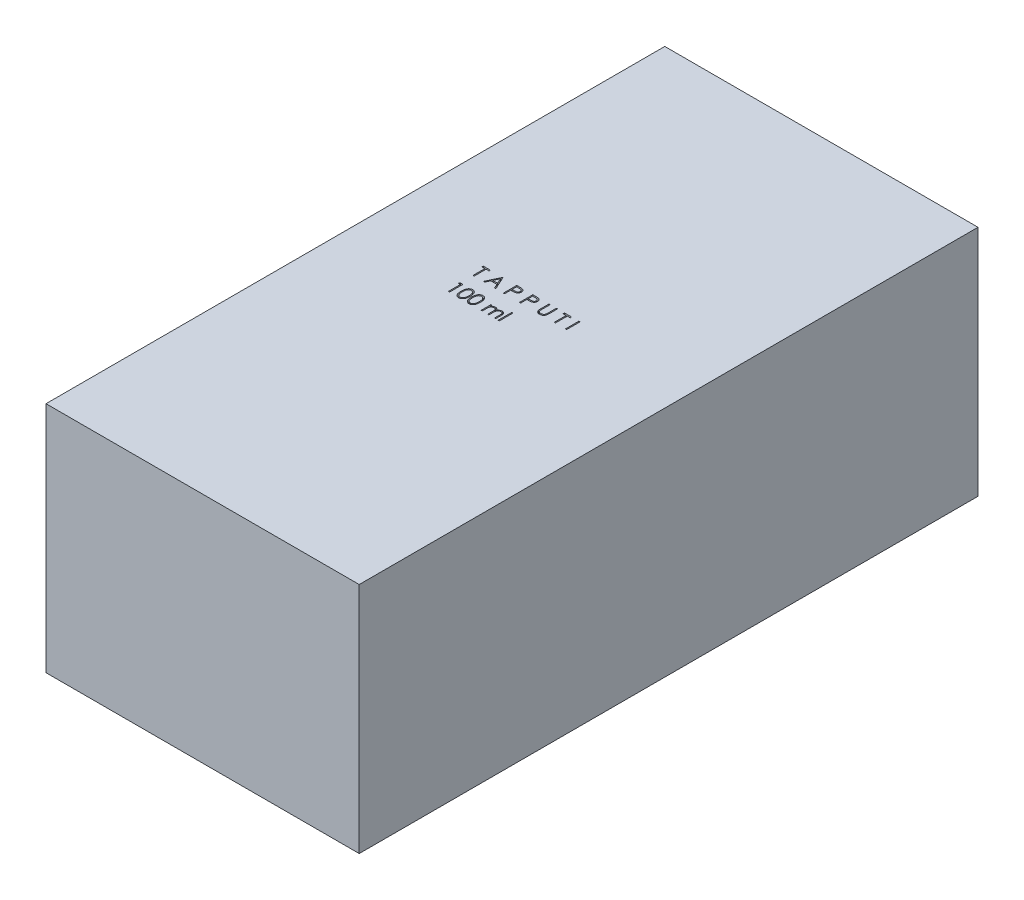
from build123d import *

# Parameters (mm, degrees)
SKETCH1_W           = 82
SKETCH1_H           = 162
BOSS_EXTRUDE1_DEPTH = 61
SKETCH3_W           = 0.314102565
SKETCH3_H           = 3.5
SKETCH3_W_2         = 0.314102564
SKETCH3_H_2         = 3.589743589
CUT_EXTRUDE1_DEPTH  = 10


with BuildPart() as part:
    # Sketch1 → Boss-Extrude1 (new body)
    with BuildSketch(Plane(origin=(0, 0, 0), x_dir=(1, 0, 0), z_dir=(0, 1, 0))):
        Rectangle(SKETCH1_W, SKETCH1_H)
    extrude(amount=-BOSS_EXTRUDE1_DEPTH)

    # Sketch3 → Cut-Extrude1 (cut)
    with BuildSketch(Plane(origin=(0, 0, 0), x_dir=(1, 0, 0), z_dir=(0, 1, 0))):
        Polygon((-14.955128205, 7.091421661), (-14.955128205, 7.45039602), (-13.115384615, 7.45039602), (-13.115384615, 7.091421661), (-13.878205128, 7.091421661), (-13.878205128, 3.95039602), (-14.192307692, 3.95039602), (-14.192307692, 7.091421661), align=None)
        Polygon((-9.794871795, 7.45039602), (-8.179487179, 3.95039602), (-8.520933494, 3.95039602), (-9.038361378, 5.072190892), (-10.625, 5.072190892), (-11.157151442, 3.95039602), (-11.5, 3.95039602), (-9.83974359, 7.45039602), align=None)
        Polygon((-9.820813301, 6.768204514), (-10.454627404, 5.431165251), (-9.203826122, 5.431165251), align=None, mode=Mode.SUBTRACT)
        with BuildLine():
            Line((-6.205128205, 7.45039602), (-5.518729968, 7.45039602))
            add(Edge.make_bspline(
                [(-5.518729968, 7.45039602), (-5.471519062, 7.450344124), (-5.381060869, 7.450244688), (-5.251345813, 7.447229942), (-5.133536082, 7.44320325), (-5.027885701, 7.437621357), (-4.934069603, 7.431024767), (-4.852512303, 7.421772727), (-4.782572747, 7.412112432), (-4.740666297, 7.402291025), (-4.721554487, 7.397811885)],
                knots=[0, 0, 0, 0, 0.000141628, 0.000271366, 0.00038923, 0.000495248, 0.00058876, 0.000671296, 0.000741499, 0.00080036, 0.00080036, 0.00080036, 0.00080036], degree=3))
            add(Edge.make_bspline(
                [(-4.721554487, 7.397811885), (-4.697360953, 7.391189936), (-4.649543976, 7.378102074), (-4.580642933, 7.35188835), (-4.515089088, 7.320806185), (-4.452657529, 7.285382245), (-4.394115446, 7.244096681), (-4.338589405, 7.198623063), (-4.286569425, 7.147911495), (-4.238348033, 7.092530755), (-4.194063235, 7.033410545), (-4.155933553, 6.969668315), (-4.124006326, 6.902377012), (-4.096623054, 6.831583441), (-4.0769146, 6.756693117), (-4.0620677, 6.678226405), (-4.052644072, 6.596191715), (-4.051741511, 6.540131847), (-4.051282051, 6.511593937)],
                knots=[0, 0, 0, 0, 7.5216e-05, 0.00014866, 0.000220794, 0.000292713, 0.000363707, 0.000435434, 0.000507823, 0.000581364, 0.000655543, 0.000729131, 0.000803767, 0.000878771, 0.000956497, 0.001035702, 0.001118238, 0.001203821, 0.001203821, 0.001203821, 0.001203821], degree=3))
            add(Edge.make_bspline(
                [(-4.051282051, 6.511593937), (-4.051703476, 6.48281616), (-4.052528022, 6.426510496), (-4.062424307, 6.344137708), (-4.075754499, 6.265419318), (-4.096251551, 6.190529867), (-4.123097224, 6.119914097), (-4.154589277, 6.052492865), (-4.192572808, 5.989413193), (-4.236217637, 5.930446075), (-4.284769232, 5.875536163), (-4.33802217, 5.825081368), (-4.395761462, 5.77937703), (-4.45780361, 5.738320686), (-4.524753459, 5.702864407), (-4.595595613, 5.671107102), (-4.670945829, 5.644436041), (-4.723088343, 5.63040598), (-4.749599359, 5.623272623)],
                knots=[0, 0, 0, 0, 8.6284e-05, 0.00016882, 0.000248587, 0.000325638, 0.000401297, 0.000474998, 0.000548586, 0.000621785, 0.0006948, 0.0007682, 0.000841564, 0.000915458, 0.000991056, 0.00106858, 0.00114819, 0.001230532, 0.001230532, 0.001230532, 0.001230532], degree=3))
            add(Edge.make_bspline(
                [(-4.749599359, 5.623272623), (-4.771526693, 5.618609641), (-4.81958172, 5.608390447), (-4.898724443, 5.59698199), (-4.990869828, 5.58724439), (-5.095892108, 5.579943252), (-5.213697013, 5.573692884), (-5.344348271, 5.56872479), (-5.488102348, 5.565994936), (-5.588373592, 5.565854143), (-5.64072516, 5.565780635)],
                knots=[0, 0, 0, 0, 6.7238e-05, 0.000147357, 0.000239727, 0.000345177, 0.000463135, 0.000593636, 0.000737393, 0.000894446, 0.000894446, 0.000894446, 0.000894446], degree=3))
            Line((-5.64072516, 5.565780635), (-5.891025641, 5.565780635))
            Line((-5.891025641, 5.565780635), (-5.891025641, 3.95039602))
            Line((-5.891025641, 3.95039602), (-6.205128205, 3.95039602))
            Line((-6.205128205, 3.95039602), (-6.205128205, 7.45039602))
        make_face()
        with BuildLine():
            Line((-5.891025641, 7.091421661), (-5.891025641, 5.924754994))
            Line((-5.891025641, 5.924754994), (-5.278245192, 5.917042655))
            add(Edge.make_bspline(
                [(-5.278245192, 5.917042655), (-5.248325266, 5.917027191), (-5.190565467, 5.916997339), (-5.107129243, 5.920982562), (-5.029719956, 5.925583095), (-4.958575381, 5.932319018), (-4.893663446, 5.941840276), (-4.834875917, 5.951452014), (-4.782668634, 5.965357376), (-4.721569433, 5.984080446), (-4.653486085, 6.016013061), (-4.579418537, 6.062362951), (-4.51664795, 6.121443659), (-4.462329654, 6.187871491), (-4.419223776, 6.26177062), (-4.387667783, 6.340839557), (-4.369126626, 6.424267406), (-4.366640432, 6.481355545), (-4.365384615, 6.510191693)],
                knots=[0, 0, 0, 0, 8.9746e-05, 0.000173253, 0.000250533, 0.00032239, 0.000387534, 0.00044736, 0.000500926, 0.000549486, 0.000638903, 0.000725641, 0.000810488, 0.000896226, 0.000982324, 0.00106604, 0.001150757, 0.001237226, 0.001237226, 0.001237226, 0.001237226], degree=3))
            add(Edge.make_bspline(
                [(-4.365384615, 6.510191693), (-4.366647262, 6.538330206), (-4.369157247, 6.594266089), (-4.38781311, 6.676244849), (-4.419162424, 6.754480554), (-4.462619018, 6.827453639), (-4.515360148, 6.893642443), (-4.576659491, 6.95113957), (-4.646372753, 6.997361273), (-4.711220984, 7.027194554), (-4.76882217, 7.04540983), (-4.81885413, 7.05815467), (-4.875344804, 7.068330277), (-4.938312584, 7.076569779), (-5.007269418, 7.083623241), (-5.082807732, 7.088409218), (-5.164641376, 7.091210674), (-5.221451947, 7.091349629), (-5.250901442, 7.091421661)],
                knots=[0, 0, 0, 0, 8.4371e-05, 0.000167719, 0.000250783, 0.000336277, 0.000421575, 0.000503926, 0.000587348, 0.000671427, 0.000717102, 0.000768457, 0.000826213, 0.000889178, 0.000958942, 0.001034123, 0.001116202, 0.001204546, 0.001204546, 0.001204546, 0.001204546], degree=3))
            Line((-5.250901442, 7.091421661), (-5.891025641, 7.091421661))
        make_face(mode=Mode.SUBTRACT)
        with BuildLine():
            Line((-1.987179487, 7.45039602), (-1.30078125, 7.45039602))
            add(Edge.make_bspline(
                [(-1.30078125, 7.45039602), (-1.253570344, 7.450344124), (-1.163112151, 7.450244688), (-1.033397095, 7.447229942), (-0.915587364, 7.44320325), (-0.809936983, 7.437621357), (-0.716120885, 7.431024767), (-0.634563585, 7.421772727), (-0.564624029, 7.412112432), (-0.522717579, 7.402291025), (-0.503605769, 7.397811885)],
                knots=[0, 0, 0, 0, 0.000141628, 0.000271366, 0.00038923, 0.000495248, 0.00058876, 0.000671296, 0.000741499, 0.00080036, 0.00080036, 0.00080036, 0.00080036], degree=3))
            add(Edge.make_bspline(
                [(-0.503605769, 7.397811885), (-0.479412235, 7.391189936), (-0.431595258, 7.378102074), (-0.362694215, 7.35188835), (-0.29714037, 7.320806185), (-0.234708811, 7.285382245), (-0.176166728, 7.244096681), (-0.120640687, 7.198623063), (-0.068620707, 7.147911495), (-0.020399315, 7.092530755), (0.023885483, 7.033410545), (0.062015165, 6.969668315), (0.093942392, 6.902377012), (0.121325664, 6.831583441), (0.141034118, 6.756693117), (0.155881018, 6.678226405), (0.165304646, 6.596191715), (0.166207207, 6.540131847), (0.166666667, 6.511593937)],
                knots=[0, 0, 0, 0, 7.5216e-05, 0.00014866, 0.000220794, 0.000292713, 0.000363707, 0.000435434, 0.000507823, 0.000581364, 0.000655543, 0.000729131, 0.000803767, 0.000878771, 0.000956497, 0.001035702, 0.001118238, 0.001203821, 0.001203821, 0.001203821, 0.001203821], degree=3))
            add(Edge.make_bspline(
                [(0.166666667, 6.511593937), (0.166245242, 6.48281616), (0.165420696, 6.426510496), (0.155524411, 6.344137708), (0.142194219, 6.265419318), (0.121697167, 6.190529867), (0.094851494, 6.119914097), (0.063359441, 6.052492865), (0.02537591, 5.989413193), (-0.018268919, 5.930446075), (-0.066820514, 5.875536163), (-0.120073452, 5.825081368), (-0.177812744, 5.77937703), (-0.239854892, 5.738320686), (-0.306804741, 5.702864407), (-0.377646895, 5.671107102), (-0.452997111, 5.644436041), (-0.505139625, 5.63040598), (-0.531650641, 5.623272623)],
                knots=[0, 0, 0, 0, 8.6284e-05, 0.00016882, 0.000248587, 0.000325638, 0.000401297, 0.000474998, 0.000548586, 0.000621785, 0.0006948, 0.0007682, 0.000841564, 0.000915458, 0.000991056, 0.00106858, 0.00114819, 0.001230532, 0.001230532, 0.001230532, 0.001230532], degree=3))
            add(Edge.make_bspline(
                [(-0.531650641, 5.623272623), (-0.553577975, 5.618609641), (-0.601633002, 5.608390447), (-0.680775725, 5.59698199), (-0.77292111, 5.58724439), (-0.87794339, 5.579943252), (-0.995748295, 5.573692884), (-1.126399553, 5.56872479), (-1.27015363, 5.565994936), (-1.370424874, 5.565854143), (-1.422776442, 5.565780635)],
                knots=[0, 0, 0, 0, 6.7238e-05, 0.000147357, 0.000239727, 0.000345177, 0.000463135, 0.000593636, 0.000737393, 0.000894446, 0.000894446, 0.000894446, 0.000894446], degree=3))
            Line((-1.422776442, 5.565780635), (-1.673076923, 5.565780635))
            Line((-1.673076923, 5.565780635), (-1.673076923, 3.95039602))
            Line((-1.673076923, 3.95039602), (-1.987179487, 3.95039602))
            Line((-1.987179487, 3.95039602), (-1.987179487, 7.45039602))
        make_face()
        with BuildLine():
            Line((-1.673076923, 7.091421661), (-1.673076923, 5.924754994))
            Line((-1.673076923, 5.924754994), (-1.060296474, 5.917042655))
            add(Edge.make_bspline(
                [(-1.060296474, 5.917042655), (-1.030376549, 5.917027191), (-0.972616749, 5.916997339), (-0.889180525, 5.920982562), (-0.811771238, 5.925583095), (-0.740626663, 5.932319018), (-0.675714728, 5.941840276), (-0.616927199, 5.951452014), (-0.564719916, 5.965357376), (-0.503620715, 5.984080446), (-0.435537367, 6.016013061), (-0.361469819, 6.062362951), (-0.298699232, 6.121443659), (-0.244380936, 6.187871491), (-0.201275058, 6.26177062), (-0.169719065, 6.340839557), (-0.151177908, 6.424267406), (-0.148691714, 6.481355545), (-0.147435897, 6.510191693)],
                knots=[0, 0, 0, 0, 8.9746e-05, 0.000173253, 0.000250533, 0.00032239, 0.000387534, 0.00044736, 0.000500926, 0.000549486, 0.000638903, 0.000725641, 0.000810488, 0.000896226, 0.000982324, 0.00106604, 0.001150757, 0.001237226, 0.001237226, 0.001237226, 0.001237226], degree=3))
            add(Edge.make_bspline(
                [(-0.147435897, 6.510191693), (-0.148698544, 6.538330206), (-0.151208529, 6.594266089), (-0.169864392, 6.676244849), (-0.201213706, 6.754480554), (-0.2446703, 6.827453639), (-0.29741143, 6.893642443), (-0.358710774, 6.95113957), (-0.428424035, 6.997361273), (-0.493272266, 7.027194554), (-0.550873452, 7.04540983), (-0.600905412, 7.05815467), (-0.657396086, 7.068330277), (-0.720363866, 7.076569779), (-0.7893207, 7.083623241), (-0.864859015, 7.088409218), (-0.946692658, 7.091210674), (-1.003503229, 7.091349629), (-1.032952724, 7.091421661)],
                knots=[0, 0, 0, 0, 8.4371e-05, 0.000167719, 0.000250783, 0.000336277, 0.000421575, 0.000503926, 0.000587348, 0.000671427, 0.000717102, 0.000768457, 0.000826213, 0.000889178, 0.000958942, 0.001034123, 0.001116202, 0.001204546, 0.001204546, 0.001204546, 0.001204546], degree=3))
            Line((-1.032952724, 7.091421661), (-1.673076923, 7.091421661))
        make_face(mode=Mode.SUBTRACT)
        with BuildLine():
            Line((2.230769231, 7.45039602), (2.544871795, 7.45039602))
            Line((2.544871795, 7.45039602), (2.544871795, 5.353340731))
            add(Edge.make_bspline(
                [(2.544871795, 5.353340731), (2.544825051, 5.323659996), (2.544736346, 5.267335685), (2.54532886, 5.187167384), (2.546988228, 5.115894925), (2.548034388, 5.053243578), (2.550361722, 4.99950083), (2.552259768, 4.954375519), (2.554700325, 4.918081317), (2.557633443, 4.896900391), (2.558894231, 4.88779586)],
                knots=[0, 0, 0, 0, 8.9042e-05, 0.000168973, 0.000240502, 0.000302917, 0.000356945, 0.000401866, 0.000438432, 0.000465999, 0.000465999, 0.000465999, 0.000465999], degree=3))
            add(Edge.make_bspline(
                [(2.558894231, 4.88779586), (2.56407169, 4.854949096), (2.574134876, 4.791106367), (2.599781254, 4.700198085), (2.635598755, 4.618266627), (2.678041797, 4.542755336), (2.733974409, 4.475765976), (2.800977944, 4.414054323), (2.882155713, 4.360082518), (2.972416318, 4.310731707), (3.069701556, 4.271066624), (3.169112822, 4.24107326), (3.269155801, 4.22279436), (3.336131966, 4.220677821), (3.369391026, 4.219626789)],
                knots=[0, 0, 0, 0, 9.971e-05, 0.000193801, 0.000282365, 0.000367504, 0.000452699, 0.000543015, 0.000639862, 0.000744331, 0.000851226, 0.000954377, 0.001055468, 0.001155185, 0.001155185, 0.001155185, 0.001155185], degree=3))
            add(Edge.make_bspline(
                [(3.369391026, 4.219626789), (3.397944766, 4.220700639), (3.454887328, 4.222842138), (3.539493759, 4.236103569), (3.621893867, 4.260004134), (3.702494547, 4.290843893), (3.778045532, 4.331591484), (3.848588974, 4.378662323), (3.911552908, 4.433873199), (3.969010906, 4.494973544), (4.019045842, 4.563913344), (4.062416983, 4.639191482), (4.097942913, 4.721940829), (4.115486438, 4.780095251), (4.124499199, 4.80997134)],
                knots=[0, 0, 0, 0, 8.5678e-05, 0.00017086, 0.000256092, 0.000342674, 0.000429242, 0.000513055, 0.000596556, 0.000679898, 0.000764179, 0.00085149, 0.000940054, 0.001033621, 0.001033621, 0.001033621, 0.001033621], degree=3))
            add(Edge.make_bspline(
                [(4.124499199, 4.80997134), (4.127499324, 4.822319915), (4.134184812, 4.849837515), (4.140431857, 4.896358805), (4.146938383, 4.951248169), (4.151452953, 5.014899982), (4.155854173, 5.087100955), (4.158487246, 5.168227212), (4.159704279, 5.257984173), (4.160066959, 5.320621335), (4.16025641, 5.353340731)],
                knots=[0, 0, 0, 0, 3.81e-05, 8.4902e-05, 0.000140649, 0.000203941, 0.000276279, 0.000357657, 0.000447412, 0.000545571, 0.000545571, 0.000545571, 0.000545571], degree=3))
            Line((4.16025641, 5.353340731), (4.16025641, 7.45039602))
            Line((4.16025641, 7.45039602), (4.474358974, 7.45039602))
            Line((4.474358974, 7.45039602), (4.474358974, 5.336513808))
            add(Edge.make_bspline(
                [(4.474358974, 5.336513808), (4.474104854, 5.298415429), (4.473608923, 5.224064127), (4.469308346, 5.115112768), (4.462451346, 5.011759786), (4.452763258, 4.91399129), (4.439926255, 4.82215713), (4.425651035, 4.735452362), (4.407471502, 4.65449937), (4.3862381, 4.578666952), (4.361964552, 4.506481439), (4.330523404, 4.437972824), (4.295098904, 4.371058424), (4.253084251, 4.306750315), (4.205872868, 4.244763762), (4.152421188, 4.185474687), (4.094497027, 4.127935641), (4.031137467, 4.073622575), (3.963386942, 4.023813898), (3.891446984, 3.980016127), (3.815870215, 3.942992509), (3.736853088, 3.912516585), (3.654361886, 3.889601986), (3.568394526, 3.87252683), (3.478755333, 3.862824532), (3.417790676, 3.861382602), (3.386919071, 3.86065243)],
                knots=[0, 0, 0, 0, 0.000114291, 0.000223047, 0.000327049, 0.000424998, 0.000517708, 0.000605194, 0.000688542, 0.000766455, 0.0008414, 0.000916717, 0.000992315, 0.001068354, 0.001146882, 0.001225836, 0.001307639, 0.001391671, 0.001475952, 0.001559641, 0.001643989, 0.001728103, 0.001813335, 0.001900511, 0.00199079, 0.002083404, 0.002083404, 0.002083404, 0.002083404], degree=3))
            add(Edge.make_bspline(
                [(3.386919071, 3.86065243), (3.353249968, 3.861437195), (3.287191309, 3.862976902), (3.189853242, 3.871799652), (3.096539045, 3.888418047), (3.006263168, 3.90957799), (2.920254671, 3.938761728), (2.837361227, 3.972859852), (2.759002546, 4.014737113), (2.683907417, 4.061330506), (2.614082661, 4.113755144), (2.549985258, 4.170895318), (2.491509387, 4.231835695), (2.439640691, 4.297236061), (2.393519806, 4.366587768), (2.353789593, 4.440087008), (2.319676349, 4.517705324), (2.302069782, 4.571658524), (2.293169071, 4.59893368)],
                knots=[0, 0, 0, 0, 0.000101022, 0.000198206, 0.000292839, 0.000385177, 0.00047608, 0.000565014, 0.000653769, 0.000742283, 0.000829923, 0.000915339, 0.000999643, 0.001082971, 0.00116542, 0.001249186, 0.001333332, 0.001419362, 0.001419362, 0.001419362, 0.001419362], degree=3))
            add(Edge.make_bspline(
                [(2.293169071, 4.59893368), (2.287991912, 4.617566255), (2.276762541, 4.657980724), (2.264737243, 4.724867212), (2.254628162, 4.80188213), (2.245122603, 4.889030748), (2.239513645, 4.986380615), (2.234596207, 5.093889531), (2.230734588, 5.211687492), (2.23075736, 5.293742008), (2.230769231, 5.336513808)],
                knots=[0, 0, 0, 0, 5.799e-05, 0.000125782, 0.000203619, 0.000291034, 0.000388694, 0.000496078, 0.000613919, 0.000742226, 0.000742226, 0.000742226, 0.000742226], degree=3))
            Line((2.230769231, 5.336513808), (2.230769231, 7.45039602))
        make_face()
        Polygon((6.314102564, 7.091421661), (6.314102564, 7.45039602), (8.153846154, 7.45039602), (8.153846154, 7.091421661), (7.391025641, 7.091421661), (7.391025641, 3.95039602), (7.076923077, 3.95039602), (7.076923077, 7.091421661), align=None)
        with Locations((10.19551282, 5.70039602)):
            Rectangle(SKETCH3_W, SKETCH3_H)
        Polygon((-14.121494391, 0.617062687), (-13.474358974, 0.617062687), (-13.474358974, -2.882937313), (-13.788461538, -2.882937313), (-13.788461538, 0.258088328), (-14.326923077, 0.258088328), align=None)
        with BuildLine():
            add(Edge.make_bspline(
                [(-12.173076923, -1.134339557), (-12.172748905, -1.078242169), (-12.172111725, -0.969272185), (-12.165023304, -0.810487543), (-12.153247962, -0.661527254), (-12.137110589, -0.522384188), (-12.117472609, -0.393022423), (-12.091257122, -0.273787666), (-12.061444319, -0.16412806), (-12.026891874, -0.063686011), (-11.987904085, 0.028891692), (-11.945469824, 0.115316893), (-11.897905029, 0.195458826), (-11.847928116, 0.270596616), (-11.793516045, 0.339500311), (-11.736217254, 0.403142973), (-11.673795378, 0.460053724), (-11.60837237, 0.511900026), (-11.539355905, 0.557349498), (-11.468713239, 0.597382236), (-11.395958133, 0.631582104), (-11.320891951, 0.658472539), (-11.244189393, 0.680683386), (-11.165582326, 0.695872334), (-11.084940962, 0.705429242), (-11.030509527, 0.70634291), (-11.002904647, 0.706806276)],
                knots=[0, 0, 0, 0, 0.000168282, 0.000326891, 0.000476705, 0.00061646, 0.000747059, 0.00086904, 0.000982494, 0.001087814, 0.001187428, 0.001283689, 0.001376399, 0.001466822, 0.001554203, 0.001639568, 0.001723424, 0.001807301, 0.001889751, 0.001971063, 0.002050735, 0.002130583, 0.002210036, 0.002290062, 0.002370508, 0.002453288, 0.002453288, 0.002453288, 0.002453288], degree=3))
            add(Edge.make_bspline(
                [(-11.002904647, 0.706806276), (-10.975069169, 0.706318461), (-10.91971316, 0.70534835), (-10.837872785, 0.696024408), (-10.757923103, 0.680553285), (-10.680204964, 0.65863231), (-10.604079978, 0.631436633), (-10.53014357, 0.597349516), (-10.457936489, 0.557670649), (-10.388606201, 0.511046772), (-10.321391586, 0.459064495), (-10.257943623, 0.400301827), (-10.198256537, 0.335352107), (-10.141581232, 0.264910243), (-10.089525634, 0.187625159), (-10.039952202, 0.104841049), (-9.995580166, 0.015110184), (-9.952845491, -0.080070284), (-9.915958504, -0.183333943), (-9.882692259, -0.294098703), (-9.85581329, -0.41367289), (-9.833424018, -0.541429135), (-9.816079122, -0.677836619), (-9.80344648, -0.822602934), (-9.796773395, -0.975823325), (-9.795516694, -1.080581174), (-9.794871795, -1.134339557)],
                knots=[0, 0, 0, 0, 8.3481e-05, 0.000166017, 0.000246731, 0.000327534, 0.000408041, 0.000488986, 0.000571522, 0.000654944, 0.000739373, 0.000826202, 0.000914021, 0.001003809, 0.001097153, 0.001193347, 0.001293057, 0.001397277, 0.001506176, 0.001621751, 0.001744038, 0.001873599, 0.002010742, 0.002156422, 0.002309427, 0.002470709, 0.002470709, 0.002470709, 0.002470709], degree=3))
            add(Edge.make_bspline(
                [(-9.794871795, -1.134339557), (-9.795523379, -1.187863465), (-9.796792965, -1.292152617), (-9.803371672, -1.444683592), (-9.816330303, -1.588681635), (-9.832540292, -1.724492098), (-9.854991255, -1.851549717), (-9.882596421, -1.970294165), (-9.913246744, -2.081238237), (-9.951081538, -2.183473048), (-9.992492248, -2.278424771), (-10.037547444, -2.36709192), (-10.08581727, -2.450258212), (-10.138406015, -2.527257959), (-10.194459429, -2.598636616), (-10.255177217, -2.663134239), (-10.318847802, -2.722304911), (-10.386260218, -2.774956538), (-10.45667177, -2.821041343), (-10.528630846, -2.862255193), (-10.60341423, -2.895487888), (-10.679327183, -2.924022929), (-10.757455549, -2.945823381), (-10.837701939, -2.960897237), (-10.919658175, -2.971469085), (-10.97505974, -2.972275565), (-11.002904647, -2.972680903)],
                knots=[0, 0, 0, 0, 0.000160581, 0.000312886, 0.000457868, 0.000594226, 0.000723097, 0.000844701, 0.000959884, 0.001068125, 0.001171421, 0.001270505, 0.001366343, 0.001459687, 0.001550023, 0.00163832, 0.001725149, 0.001810562, 0.001894568, 0.001977446, 0.00205903, 0.002139777, 0.00222058, 0.002301983, 0.002384599, 0.00246808, 0.00246808, 0.00246808, 0.00246808], degree=3))
            add(Edge.make_bspline(
                [(-11.002904647, -2.972680903), (-11.030508761, -2.972214548), (-11.084938686, -2.971294986), (-11.165591112, -2.961781254), (-11.243873555, -2.946485751), (-11.320172309, -2.925069147), (-11.394878824, -2.898854311), (-11.466975111, -2.864700627), (-11.537262795, -2.825366558), (-11.605554351, -2.780571137), (-11.670566512, -2.729249453), (-11.732665117, -2.672485165), (-11.790290136, -2.608861754), (-11.843924232, -2.53938383), (-11.89489832, -2.464690588), (-11.941787693, -2.383762215), (-11.985158547, -2.296919605), (-12.024802038, -2.203601694), (-12.059950701, -2.102446766), (-12.090998409, -1.992297588), (-12.115512567, -1.872181951), (-12.136495522, -1.743064584), (-12.153419905, -1.604390654), (-12.164974231, -1.456084876), (-12.172115546, -1.298239667), (-12.172750616, -1.189969892), (-12.173076923, -1.134339557)],
                knots=[0, 0, 0, 0, 8.278e-05, 0.000163226, 0.000243252, 0.00032184, 0.00040079, 0.000480463, 0.00056082, 0.000642298, 0.000725191, 0.000809047, 0.000894412, 0.000982346, 0.001072188, 0.001165503, 0.001262704, 0.001363236, 0.001469448, 0.001583766, 0.001706286, 0.001836995, 0.001976138, 0.002125253, 0.002283161, 0.002450041, 0.002450041, 0.002450041, 0.002450041], degree=3))
        make_face()
        with BuildLine():
            add(Edge.make_bspline(
                [(-11.858974359, -1.132937313), (-11.858854912, -1.179686012), (-11.858623089, -1.270416057), (-11.852566888, -1.402259318), (-11.844316656, -1.525229647), (-11.833675359, -1.639483183), (-11.81787241, -1.744633196), (-11.800165622, -1.841402879), (-11.778617533, -1.929280116), (-11.753122515, -2.008867927), (-11.724083418, -2.081516995), (-11.692377554, -2.14911821), (-11.658316832, -2.212470147), (-11.620197681, -2.271003755), (-11.578682618, -2.324909919), (-11.534709359, -2.375142751), (-11.486636774, -2.419939733), (-11.420133032, -2.473666588), (-11.332336557, -2.529185722), (-11.221716102, -2.577531811), (-11.108047651, -2.607914268), (-11.030896401, -2.611778024), (-10.992387821, -2.613706544)],
                knots=[0, 0, 0, 0, 0.000140231, 0.000272162, 0.000395845, 0.00050998, 0.000616273, 0.00071473, 0.000805025, 0.000887508, 0.000965234, 0.00103957, 0.001111417, 0.001180842, 0.001248855, 0.001315406, 0.001380877, 0.0014457, 0.001571746, 0.00169106, 0.001806864, 0.001922266, 0.001922266, 0.001922266, 0.001922266], degree=3))
            add(Edge.make_bspline(
                [(-10.992387821, -2.613706544), (-10.953630149, -2.612108763), (-10.876194826, -2.608916501), (-10.763061031, -2.578117763), (-10.65323076, -2.531648224), (-10.56715882, -2.476700718), (-10.501676277, -2.424372389), (-10.454759287, -2.379757741), (-10.411697238, -2.329801873), (-10.370855163, -2.275902577), (-10.333396088, -2.217030093), (-10.29933295, -2.153467518), (-10.268249602, -2.08503834), (-10.250540556, -2.037268601), (-10.241486378, -2.012845166)],
                knots=[0, 0, 0, 0, 0.000116044, 0.000231848, 0.000349318, 0.000472837, 0.000536674, 0.000600645, 0.000666733, 0.000734322, 0.000803367, 0.000875831, 0.000950509, 0.001028633, 0.001028633, 0.001028633, 0.001028633], degree=3))
            add(Edge.make_bspline(
                [(-10.241486378, -2.012845166), (-10.23093461, -1.981615426), (-10.209509997, -1.918205662), (-10.181898222, -1.81984201), (-10.160152823, -1.716639246), (-10.140589457, -1.60921413), (-10.127236401, -1.496774428), (-10.116488588, -1.379668045), (-10.110157901, -1.257806682), (-10.10937315, -1.175011691), (-10.108974359, -1.132937313)],
                knots=[0, 0, 0, 0, 9.8886e-05, 0.00020078, 0.000306259, 0.000415188, 0.00052824, 0.000645799, 0.000767957, 0.000894177, 0.000894177, 0.000894177, 0.000894177], degree=3))
            add(Edge.make_bspline(
                [(-10.108974359, -1.132937313), (-10.109524548, -1.090869741), (-10.110600836, -1.008576576), (-10.114714824, -0.888058395), (-10.125338398, -0.773590635), (-10.137137517, -0.664680162), (-10.154534738, -0.561929859), (-10.173292545, -0.464479554), (-10.198493757, -0.373536529), (-10.225413532, -0.287676947), (-10.256223928, -0.207876293), (-10.290139662, -0.133762506), (-10.326361421, -0.064977782), (-10.365703661, -0.00171084), (-10.407699344, 0.056321703), (-10.453456894, 0.107956297), (-10.501161266, 0.154793265), (-10.567978452, 0.208255835), (-10.655452742, 0.26276753), (-10.764298389, 0.31293329), (-10.877569034, 0.341741582), (-10.954142488, 0.34580327), (-10.992387821, 0.347831917)],
                knots=[0, 0, 0, 0, 0.000126219, 0.000246912, 0.000361616, 0.00047102, 0.00057545, 0.000674176, 0.000768567, 0.000858368, 0.000944043, 0.001024988, 0.001102772, 0.001177091, 0.00124833, 0.001317386, 0.001383826, 0.001448649, 0.001573728, 0.001692043, 0.001806995, 0.001921698, 0.001921698, 0.001921698, 0.001921698], degree=3))
            add(Edge.make_bspline(
                [(-10.992387821, 0.347831917), (-11.031098413, 0.345800471), (-11.108590118, 0.341733877), (-11.223038073, 0.313040623), (-11.332742425, 0.263027657), (-11.419985399, 0.208075285), (-11.486849186, 0.155736973), (-11.533931879, 0.110350519), (-11.578078051, 0.060704265), (-11.618745751, 0.00630235), (-11.656835035, -0.052163017), (-11.691816047, -0.115151782), (-11.723333377, -0.182983146), (-11.752417913, -0.255599582), (-11.777990701, -0.335180526), (-11.799084664, -0.42294952), (-11.818571717, -0.519411412), (-11.832366986, -0.62513092), (-11.844630742, -0.739413073), (-11.85251209, -0.862690391), (-11.858643348, -0.994754772), (-11.858861812, -1.08595393), (-11.858974359, -1.132937313)],
                knots=[0, 0, 0, 0, 0.000116101, 0.000232413, 0.000351368, 0.000476447, 0.000540832, 0.000605795, 0.000672346, 0.000739935, 0.00080936, 0.000881545, 0.00095588, 0.001033607, 0.001116089, 0.001206384, 0.001304286, 0.001411174, 0.001526077, 0.001649061, 0.001781692, 0.001922624, 0.001922624, 0.001922624, 0.001922624], degree=3))
        make_face(mode=Mode.SUBTRACT)
        with BuildLine():
            add(Edge.make_bspline(
                [(-9.480769231, -1.134339557), (-9.480441213, -1.078242169), (-9.479804033, -0.969272185), (-9.472715612, -0.810487543), (-9.460940269, -0.661527254), (-9.444802897, -0.522384188), (-9.425164916, -0.393022423), (-9.39894943, -0.273787666), (-9.369136627, -0.16412806), (-9.334584181, -0.063686011), (-9.295596392, 0.028891692), (-9.253162132, 0.115316893), (-9.205597337, 0.195458826), (-9.155620424, 0.270596616), (-9.101208353, 0.339500311), (-9.043909562, 0.403142973), (-8.981487686, 0.460053724), (-8.916064678, 0.511900026), (-8.847048213, 0.557349498), (-8.776405547, 0.597382236), (-8.703650441, 0.631582104), (-8.628584258, 0.658472539), (-8.5518817, 0.680683386), (-8.473274634, 0.695872334), (-8.39263327, 0.705429242), (-8.338201835, 0.70634291), (-8.310596955, 0.706806276)],
                knots=[0, 0, 0, 0, 0.000168282, 0.000326891, 0.000476705, 0.00061646, 0.000747059, 0.00086904, 0.000982494, 0.001087814, 0.001187428, 0.001283689, 0.001376399, 0.001466822, 0.001554203, 0.001639568, 0.001723424, 0.001807301, 0.001889751, 0.001971063, 0.002050735, 0.002130583, 0.002210036, 0.002290062, 0.002370508, 0.002453288, 0.002453288, 0.002453288, 0.002453288], degree=3))
            add(Edge.make_bspline(
                [(-8.310596955, 0.706806276), (-8.282761477, 0.706318461), (-8.227405468, 0.70534835), (-8.145565093, 0.696024408), (-8.065615411, 0.680553285), (-7.987897272, 0.65863231), (-7.911772286, 0.631436633), (-7.837835878, 0.597349516), (-7.765628796, 0.557670649), (-7.696298509, 0.511046772), (-7.629083893, 0.459064495), (-7.56563593, 0.400301827), (-7.505948845, 0.335352107), (-7.449273539, 0.264910243), (-7.397217942, 0.187625159), (-7.34764451, 0.104841049), (-7.303272474, 0.015110184), (-7.260537799, -0.080070284), (-7.223650812, -0.183333943), (-7.190384567, -0.294098703), (-7.163505598, -0.41367289), (-7.141116326, -0.541429135), (-7.12377143, -0.677836619), (-7.111138788, -0.822602934), (-7.104465703, -0.975823325), (-7.103209001, -1.080581174), (-7.102564103, -1.134339557)],
                knots=[0, 0, 0, 0, 8.3481e-05, 0.000166017, 0.000246731, 0.000327534, 0.000408041, 0.000488986, 0.000571522, 0.000654944, 0.000739373, 0.000826202, 0.000914021, 0.001003809, 0.001097153, 0.001193347, 0.001293057, 0.001397277, 0.001506176, 0.001621751, 0.001744038, 0.001873599, 0.002010742, 0.002156422, 0.002309427, 0.002470709, 0.002470709, 0.002470709, 0.002470709], degree=3))
            add(Edge.make_bspline(
                [(-7.102564103, -1.134339557), (-7.103215687, -1.187863465), (-7.104485273, -1.292152617), (-7.11106398, -1.444683592), (-7.124022611, -1.588681635), (-7.140232599, -1.724492098), (-7.162683562, -1.851549717), (-7.190288728, -1.970294165), (-7.220939051, -2.081238237), (-7.258773845, -2.183473048), (-7.300184556, -2.278424771), (-7.345239752, -2.36709192), (-7.393509578, -2.450258212), (-7.446098323, -2.527257959), (-7.502151736, -2.598636616), (-7.562869525, -2.663134239), (-7.62654011, -2.722304911), (-7.693952526, -2.774956538), (-7.764364077, -2.821041343), (-7.836323154, -2.862255193), (-7.911106537, -2.895487888), (-7.98701949, -2.924022929), (-8.065147856, -2.945823381), (-8.145394247, -2.960897237), (-8.227350483, -2.971469085), (-8.282752048, -2.972275565), (-8.310596955, -2.972680903)],
                knots=[0, 0, 0, 0, 0.000160581, 0.000312886, 0.000457868, 0.000594226, 0.000723097, 0.000844701, 0.000959884, 0.001068125, 0.001171421, 0.001270505, 0.001366343, 0.001459687, 0.001550023, 0.00163832, 0.001725149, 0.001810562, 0.001894568, 0.001977446, 0.00205903, 0.002139777, 0.00222058, 0.002301983, 0.002384599, 0.00246808, 0.00246808, 0.00246808, 0.00246808], degree=3))
            add(Edge.make_bspline(
                [(-8.310596955, -2.972680903), (-8.338201069, -2.972214548), (-8.392630994, -2.971294986), (-8.473283419, -2.961781254), (-8.551565863, -2.946485751), (-8.627864617, -2.925069147), (-8.702571132, -2.898854311), (-8.774667419, -2.864700627), (-8.844955102, -2.825366558), (-8.913246658, -2.780571137), (-8.978258819, -2.729249453), (-9.040357425, -2.672485165), (-9.097982444, -2.608861754), (-9.151616539, -2.53938383), (-9.202590628, -2.464690588), (-9.249480001, -2.383762215), (-9.292850855, -2.296919605), (-9.332494346, -2.203601694), (-9.367643009, -2.102446766), (-9.398690717, -1.992297588), (-9.423204875, -1.872181951), (-9.44418783, -1.743064584), (-9.461112213, -1.604390654), (-9.472666538, -1.456084876), (-9.479807853, -1.298239667), (-9.480442924, -1.189969892), (-9.480769231, -1.134339557)],
                knots=[0, 0, 0, 0, 8.278e-05, 0.000163226, 0.000243252, 0.00032184, 0.00040079, 0.000480463, 0.00056082, 0.000642298, 0.000725191, 0.000809047, 0.000894412, 0.000982346, 0.001072188, 0.001165503, 0.001262704, 0.001363236, 0.001469448, 0.001583766, 0.001706286, 0.001836995, 0.001976138, 0.002125253, 0.002283161, 0.002450041, 0.002450041, 0.002450041, 0.002450041], degree=3))
        make_face()
        with BuildLine():
            add(Edge.make_bspline(
                [(-9.166666667, -1.132937313), (-9.16654722, -1.179686012), (-9.166315396, -1.270416057), (-9.160259196, -1.402259318), (-9.152008964, -1.525229647), (-9.141367667, -1.639483183), (-9.125564718, -1.744633196), (-9.10785793, -1.841402879), (-9.086309841, -1.929280116), (-9.060814823, -2.008867927), (-9.031775726, -2.081516995), (-9.000069862, -2.14911821), (-8.966009139, -2.212470147), (-8.927889989, -2.271003755), (-8.886374925, -2.324909919), (-8.842401666, -2.375142751), (-8.794329082, -2.419939733), (-8.72782534, -2.473666588), (-8.640028865, -2.529185722), (-8.52940841, -2.577531811), (-8.415739959, -2.607914268), (-8.338588709, -2.611778024), (-8.300080128, -2.613706544)],
                knots=[0, 0, 0, 0, 0.000140231, 0.000272162, 0.000395845, 0.00050998, 0.000616273, 0.00071473, 0.000805025, 0.000887508, 0.000965234, 0.00103957, 0.001111417, 0.001180842, 0.001248855, 0.001315406, 0.001380877, 0.0014457, 0.001571746, 0.00169106, 0.001806864, 0.001922266, 0.001922266, 0.001922266, 0.001922266], degree=3))
            add(Edge.make_bspline(
                [(-8.300080128, -2.613706544), (-8.261322457, -2.612108763), (-8.183887133, -2.608916501), (-8.070753338, -2.578117763), (-7.960923068, -2.531648224), (-7.874851128, -2.476700718), (-7.809368584, -2.424372389), (-7.762451594, -2.379757741), (-7.719389546, -2.329801873), (-7.678547471, -2.275902577), (-7.641088395, -2.217030093), (-7.607025258, -2.153467518), (-7.57594191, -2.08503834), (-7.558232864, -2.037268601), (-7.549178686, -2.012845166)],
                knots=[0, 0, 0, 0, 0.000116044, 0.000231848, 0.000349318, 0.000472837, 0.000536674, 0.000600645, 0.000666733, 0.000734322, 0.000803367, 0.000875831, 0.000950509, 0.001028633, 0.001028633, 0.001028633, 0.001028633], degree=3))
            add(Edge.make_bspline(
                [(-7.549178686, -2.012845166), (-7.538626918, -1.981615426), (-7.517202304, -1.918205662), (-7.48959053, -1.81984201), (-7.467845131, -1.716639246), (-7.448281765, -1.60921413), (-7.434928709, -1.496774428), (-7.424180896, -1.379668045), (-7.417850209, -1.257806682), (-7.417065458, -1.175011691), (-7.416666667, -1.132937313)],
                knots=[0, 0, 0, 0, 9.8886e-05, 0.00020078, 0.000306259, 0.000415188, 0.00052824, 0.000645799, 0.000767957, 0.000894177, 0.000894177, 0.000894177, 0.000894177], degree=3))
            add(Edge.make_bspline(
                [(-7.416666667, -1.132937313), (-7.417216856, -1.090869741), (-7.418293144, -1.008576576), (-7.422407131, -0.888058395), (-7.433030706, -0.773590635), (-7.444829825, -0.664680162), (-7.462227046, -0.561929859), (-7.480984853, -0.464479554), (-7.506186065, -0.373536529), (-7.53310584, -0.287676947), (-7.563916235, -0.207876293), (-7.59783197, -0.133762506), (-7.634053729, -0.064977782), (-7.673395969, -0.00171084), (-7.715391652, 0.056321703), (-7.761149201, 0.107956297), (-7.808853574, 0.154793265), (-7.87567076, 0.208255835), (-7.96314505, 0.26276753), (-8.071990697, 0.31293329), (-8.185261341, 0.341741582), (-8.261834795, 0.34580327), (-8.300080128, 0.347831917)],
                knots=[0, 0, 0, 0, 0.000126219, 0.000246912, 0.000361616, 0.00047102, 0.00057545, 0.000674176, 0.000768567, 0.000858368, 0.000944043, 0.001024988, 0.001102772, 0.001177091, 0.00124833, 0.001317386, 0.001383826, 0.001448649, 0.001573728, 0.001692043, 0.001806995, 0.001921698, 0.001921698, 0.001921698, 0.001921698], degree=3))
            add(Edge.make_bspline(
                [(-8.300080128, 0.347831917), (-8.33879072, 0.345800471), (-8.416282426, 0.341733877), (-8.530730381, 0.313040623), (-8.640434732, 0.263027657), (-8.727677707, 0.208075285), (-8.794541493, 0.155736973), (-8.841624187, 0.110350519), (-8.885770359, 0.060704265), (-8.926438059, 0.00630235), (-8.964527342, -0.052163017), (-8.999508355, -0.115151782), (-9.031025685, -0.182983146), (-9.060110221, -0.255599582), (-9.085683009, -0.335180526), (-9.106776972, -0.42294952), (-9.126264025, -0.519411412), (-9.140059294, -0.62513092), (-9.15232305, -0.739413073), (-9.160204398, -0.862690391), (-9.166335655, -0.994754772), (-9.16655412, -1.08595393), (-9.166666667, -1.132937313)],
                knots=[0, 0, 0, 0, 0.000116101, 0.000232413, 0.000351368, 0.000476447, 0.000540832, 0.000605795, 0.000672346, 0.000739935, 0.00080936, 0.000881545, 0.00095588, 0.001033607, 0.001116089, 0.001206384, 0.001304286, 0.001411174, 0.001526077, 0.001649061, 0.001781692, 0.001922624, 0.001922624, 0.001922624, 0.001922624], degree=3))
        make_face(mode=Mode.SUBTRACT)
        with BuildLine():
            Line((-5.217948718, -0.325245006), (-4.903846154, -0.325245006))
            Line((-4.903846154, -0.325245006), (-4.903846154, -0.769756224))
            add(Edge.make_bspline(
                [(-4.903846154, -0.769756224), (-4.875562204, -0.730868622), (-4.821367444, -0.656356249), (-4.732501792, -0.558165965), (-4.643725679, -0.47483781), (-4.579792298, -0.431094938), (-4.549078526, -0.410080743)],
                knots=[0, 0, 0, 0, 0.000144152, 0.000276209, 0.000396804, 0.000508302, 0.000508302, 0.000508302, 0.000508302], degree=3))
            add(Edge.make_bspline(
                [(-4.549078526, -0.410080743), (-4.507213863, -0.390075378), (-4.424215964, -0.350414164), (-4.292796739, -0.310180605), (-4.158322069, -0.285455504), (-4.067513855, -0.282074131), (-4.021834936, -0.280373211)],
                knots=[0, 0, 0, 0, 0.000139031, 0.000275633, 0.000410962, 0.000547939, 0.000547939, 0.000547939, 0.000547939], degree=3))
            add(Edge.make_bspline(
                [(-4.021834936, -0.280373211), (-3.990941939, -0.281418502), (-3.92980636, -0.283487076), (-3.83922227, -0.296947111), (-3.751363658, -0.320213284), (-3.666749629, -0.352620608), (-3.58702895, -0.391867295), (-3.513939752, -0.437917003), (-3.448315544, -0.489614078), (-3.390189493, -0.549293011), (-3.337920467, -0.61862961), (-3.28984162, -0.699493859), (-3.245416408, -0.79370152), (-3.220795099, -0.862068061), (-3.207832532, -0.898061512)],
                knots=[0, 0, 0, 0, 9.2678e-05, 0.000183405, 0.000274048, 0.000364807, 0.000454797, 0.00054019, 0.000623517, 0.000704829, 0.000789387, 0.000883415, 0.000986597, 0.001101318, 0.001101318, 0.001101318, 0.001101318], degree=3))
            add(Edge.make_bspline(
                [(-3.207832532, -0.898061512), (-3.194121281, -0.873337093), (-3.167139464, -0.824682908), (-3.121833827, -0.755824646), (-3.07436603, -0.691417854), (-3.024331537, -0.631411429), (-2.97190695, -0.576101699), (-2.91684555, -0.525305797), (-2.859460768, -0.478805584), (-2.779668528, -0.424482424), (-2.675855921, -0.366781243), (-2.544967806, -0.316752799), (-2.408817635, -0.28583667), (-2.316399937, -0.282206398), (-2.269731571, -0.280373211)],
                knots=[0, 0, 0, 0, 8.4789e-05, 0.000166854, 0.000247064, 0.000324714, 0.000401089, 0.000475513, 0.000549314, 0.000622436, 0.0007649, 0.000904487, 0.001041601, 0.001181469, 0.001181469, 0.001181469, 0.001181469], degree=3))
            add(Edge.make_bspline(
                [(-2.269731571, -0.280373211), (-2.226850108, -0.281990432), (-2.142926921, -0.28515549), (-2.020749656, -0.310008963), (-1.90680785, -0.35268661), (-1.801330774, -0.410920247), (-1.706170961, -0.48409943), (-1.623454652, -0.571168268), (-1.553684288, -0.671510891), (-1.508105649, -0.76590288), (-1.477190384, -0.849238212), (-1.45812915, -0.920244504), (-1.441289455, -0.998396057), (-1.42730821, -1.083786318), (-1.417089658, -1.176716926), (-1.409518942, -1.277035802), (-1.404394869, -1.384820914), (-1.404032796, -1.459186414), (-1.403846154, -1.497520647)],
                knots=[0, 0, 0, 0, 0.000128581, 0.000251645, 0.00037211, 0.000492305, 0.000611786, 0.000730807, 0.000851198, 0.000976936, 0.001044145, 0.001117629, 0.001197252, 0.00128393, 0.001377074, 0.001477631, 0.001585715, 0.001700707, 0.001700707, 0.001700707, 0.001700707], degree=3))
            Line((-1.403846154, -1.497520647), (-1.403846154, -2.882937313))
            Line((-1.403846154, -2.882937313), (-1.717948718, -2.882937313))
            Line((-1.717948718, -2.882937313), (-1.717948718, -1.496118403))
            add(Edge.make_bspline(
                [(-1.717948718, -1.496118403), (-1.718026601, -1.463397829), (-1.71817628, -1.400513862), (-1.720869912, -1.310261411), (-1.725945226, -1.227993054), (-1.731879865, -1.153820966), (-1.740123674, -1.087572177), (-1.750769606, -1.029379759), (-1.762047286, -0.978785947), (-1.780783277, -0.9226999), (-1.810731168, -0.860829689), (-1.856348648, -0.794106113), (-1.913818755, -0.736025313), (-1.980178911, -0.685606996), (-2.055727356, -0.644613355), (-2.138992079, -0.615337346), (-2.229456131, -0.597214467), (-2.292078919, -0.595408452), (-2.324419071, -0.594475775)],
                knots=[0, 0, 0, 0, 9.816e-05, 0.000188648, 0.000270826, 0.000345412, 0.000411852, 0.000470988, 0.000522857, 0.0005672, 0.000648106, 0.000728233, 0.000808554, 0.000892128, 0.000977461, 0.001065278, 0.001156029, 0.001252946, 0.001252946, 0.001252946, 0.001252946], degree=3))
            add(Edge.make_bspline(
                [(-2.324419071, -0.594475775), (-2.364089025, -0.595891932), (-2.442491936, -0.598690798), (-2.556937422, -0.627264671), (-2.666908439, -0.670344921), (-2.769123572, -0.732777378), (-2.863151362, -0.807585742), (-2.94405094, -0.896535338), (-3.010883126, -0.997165265), (-3.056137102, -1.090311967), (-3.084726403, -1.173981411), (-3.103603319, -1.247078783), (-3.11828671, -1.330160351), (-3.132057239, -1.422667842), (-3.141044967, -1.525238022), (-3.14921334, -1.637396423), (-3.153034203, -1.759480383), (-3.153568661, -1.844107071), (-3.153846154, -1.888045486)],
                knots=[0, 0, 0, 0, 0.000118788, 0.00023477, 0.000351815, 0.000471937, 0.000592603, 0.000711217, 0.000831002, 0.000953929, 0.001020668, 0.001096002, 0.00118016, 0.001273662, 0.001376495, 0.001488939, 0.001611007, 0.001742825, 0.001742825, 0.001742825, 0.001742825], degree=3))
            Line((-3.153846154, -1.888045486), (-3.153846154, -2.882937313))
            Line((-3.153846154, -2.882937313), (-3.467948718, -2.882937313))
            Line((-3.467948718, -2.882937313), (-3.467948718, -1.582356384))
            add(Edge.make_bspline(
                [(-3.467948718, -1.582356384), (-3.468028149, -1.545663065), (-3.468180966, -1.475068808), (-3.470857283, -1.373835133), (-3.475943905, -1.281754053), (-3.481824454, -1.198932589), (-3.490284632, -1.12552126), (-3.499894394, -1.061126502), (-3.511243005, -1.005909751), (-3.530032889, -0.945346366), (-3.558747358, -0.878625443), (-3.60493562, -0.807484422), (-3.6625432, -0.745216324), (-3.730114076, -0.692057576), (-3.806119758, -0.648116095), (-3.890103159, -0.616456343), (-3.981308072, -0.598032053), (-4.044185778, -0.595683556), (-4.076522436, -0.594475775)],
                knots=[0, 0, 0, 0, 0.000110078, 0.00021178, 0.000303758, 0.00038673, 0.000460827, 0.00052538, 0.000582037, 0.000629718, 0.00071543, 0.000799052, 0.000882908, 0.000968755, 0.001056067, 0.001145266, 0.001236843, 0.001333803, 0.001333803, 0.001333803, 0.001333803], degree=3))
            add(Edge.make_bspline(
                [(-4.076522436, -0.594475775), (-4.114538647, -0.596006235), (-4.190303607, -0.599056387), (-4.301605576, -0.626510661), (-4.40909126, -0.669514736), (-4.511045959, -0.729174555), (-4.604720107, -0.803073634), (-4.686728374, -0.889988529), (-4.7556709, -0.988837563), (-4.801402715, -1.081002079), (-4.830901189, -1.162575354), (-4.850496524, -1.231926302), (-4.867336149, -1.30892655), (-4.879850171, -1.393813661), (-4.891930587, -1.486034756), (-4.897760896, -1.586049245), (-4.903432458, -1.693771333), (-4.903704873, -1.768143878), (-4.903846154, -1.806715358)],
                knots=[0, 0, 0, 0, 0.000113893, 0.000226985, 0.000341817, 0.000460265, 0.000580056, 0.000698595, 0.000817435, 0.000940348, 0.001005999, 0.001077458, 0.001156396, 0.001242271, 0.001334801, 0.001435306, 0.00154269, 0.001658383, 0.001658383, 0.001658383, 0.001658383], degree=3))
            Line((-4.903846154, -1.806715358), (-4.903846154, -2.882937313))
            Line((-4.903846154, -2.882937313), (-5.217948718, -2.882937313))
            Line((-5.217948718, -2.882937313), (-5.217948718, -0.325245006))
        make_face()
        with Locations((-0.573717949, -1.088065519)):
            Rectangle(SKETCH3_W_2, SKETCH3_H_2)
    extrude(amount=-CUT_EXTRUDE1_DEPTH, mode=Mode.SUBTRACT)


solid = part.part
